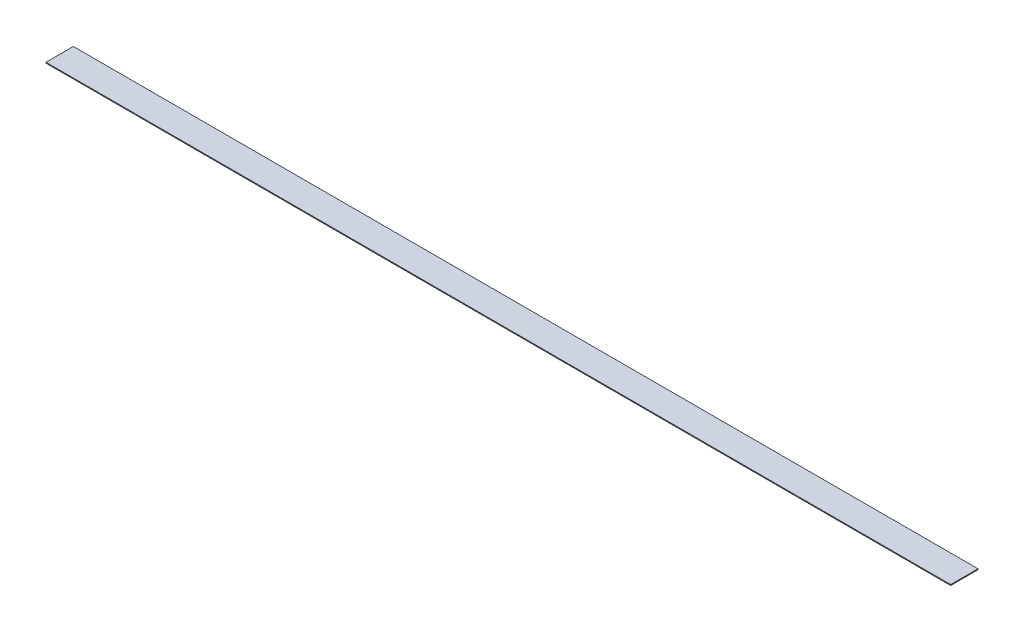
from build123d import *

# Parameters (mm, degrees)
SKETCH1_W           = 1682.75
SKETCH1_H           = 50.8
BOSS_EXTRUDE1_DEPTH = 1.5875


with BuildPart() as part:
    # Sketch1 → Boss-Extrude1 (new body)
    with BuildSketch(Plane(origin=(0, 0, 0), x_dir=(1, 0, 0), z_dir=(0, 1, 0))):
        with Locations((841.375, 25.4)):
            Rectangle(SKETCH1_W, SKETCH1_H)
    extrude(amount=BOSS_EXTRUDE1_DEPTH)


solid = part.part
